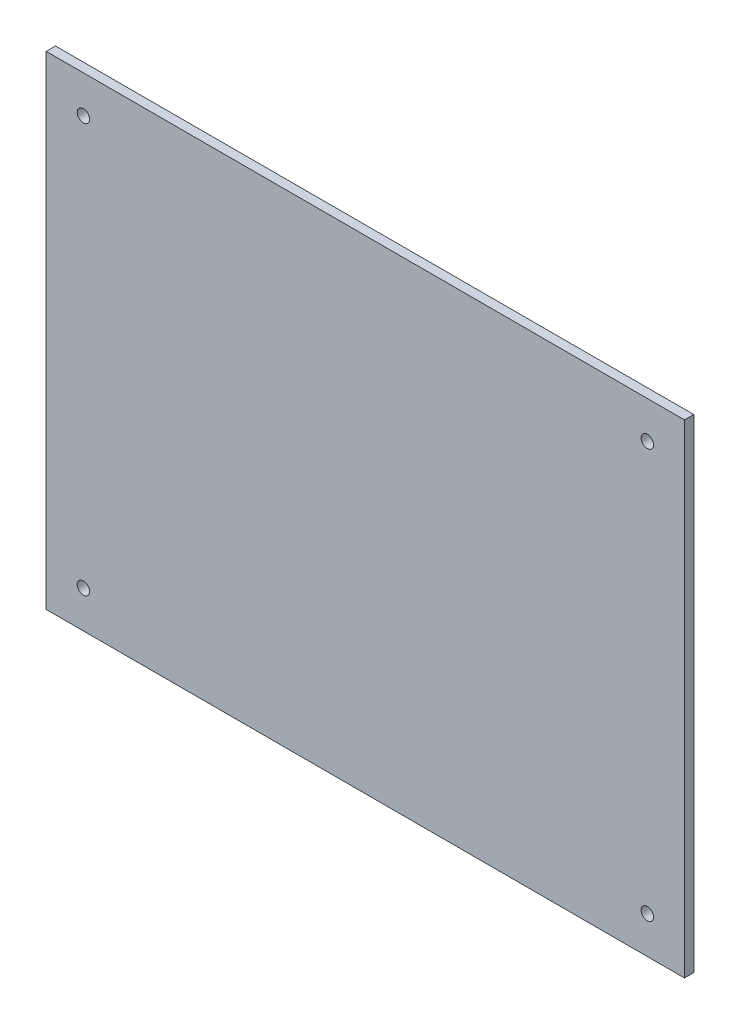
from build123d import *

# Parameters (mm, degrees)
ESQUISSE1_W             = 206
ESQUISSE1_H             = 156
BOSS_EXTRU_1_DEPTH      = 3
ESQUISSE2_R             = 2
ENL_V_MAT_EXTRU_1_DEPTH = 3


with BuildPart() as part:
    # Esquisse1 → Boss.-Extru.1 (new body)
    with BuildSketch(Plane.XY):
        with Locations((103, 78)):
            Rectangle(ESQUISSE1_W, ESQUISSE1_H)
    extrude(amount=BOSS_EXTRU_1_DEPTH)

    # Esquisse2 → Enlèv. mat.-Extru.1 (cut)
    with BuildSketch(Plane.XY.offset(3)):
        with Locations((12, 144)):
            Circle(ESQUISSE2_R)
        with Locations((194, 144)):
            Circle(ESQUISSE2_R)
        with Locations((194, 12)):
            Circle(ESQUISSE2_R)
        with Locations((12, 12)):
            Circle(ESQUISSE2_R)
    extrude(amount=-ENL_V_MAT_EXTRU_1_DEPTH, mode=Mode.SUBTRACT)


solid = part.part
